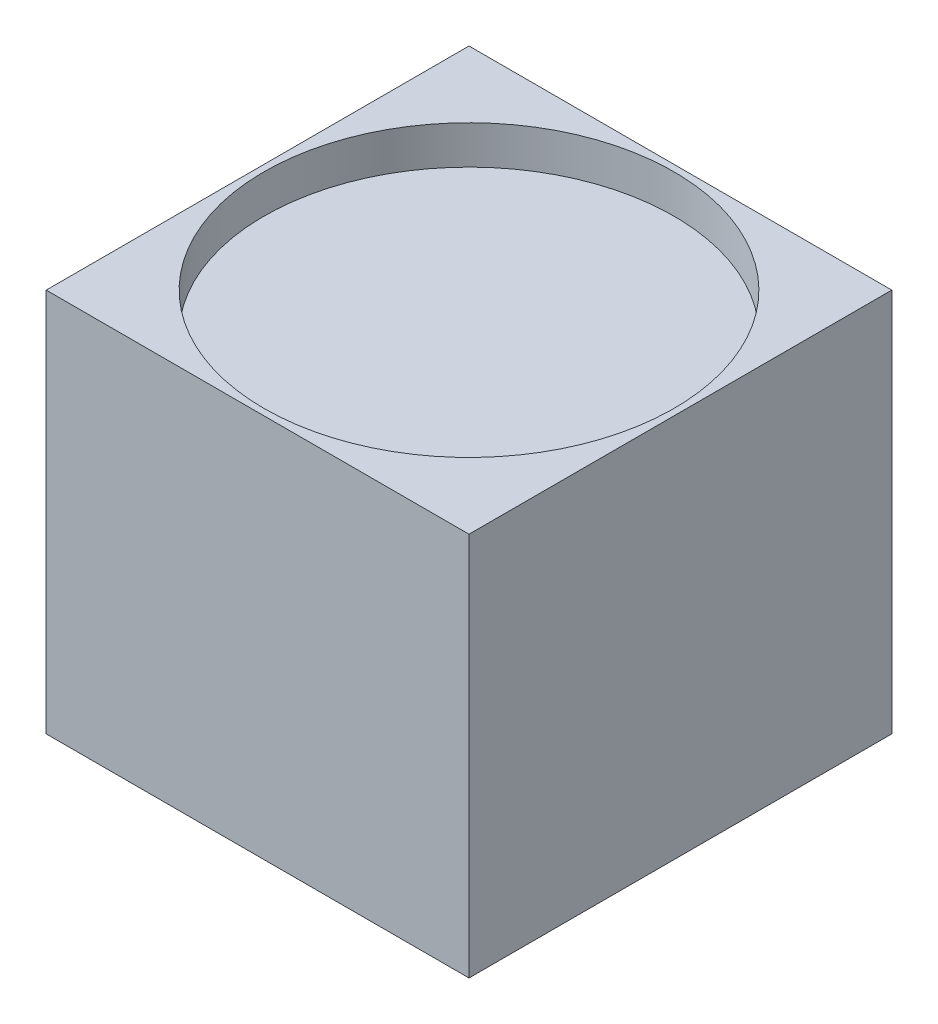
from build123d import *

# Parameters (mm, degrees)
SKETCH1_W           = 33
SKETCH1_H           = 33
BOSS_EXTRUDE1_DEPTH = 30
SKETCH2_R           = 16
CUT_EXTRUDE1_DEPTH  = 3
SKETCH3_R           = 1
CUT_EXTRUDE2_DEPTH  = 2
FILLET1_R           = 1


with BuildPart() as part:
    # Sketch1 → Boss-Extrude1 (new body)
    with BuildSketch(Plane(origin=(0, 0, 0), x_dir=(1, 0, 0), z_dir=(0, 1, 0))):
        Rectangle(SKETCH1_W, SKETCH1_H)
    extrude(amount=BOSS_EXTRUDE1_DEPTH)

    # Sketch2 → Cut-Extrude1 (cut)
    with BuildSketch(Plane(origin=(0, 30, 0), x_dir=(1, 0, 0), z_dir=(0, 1, 0))):
        Circle(SKETCH2_R)
    extrude(amount=-CUT_EXTRUDE1_DEPTH, mode=Mode.SUBTRACT)

    # Sketch3 → Cut-Extrude2 (cut)
    with BuildSketch(Plane.XZ):
        Circle(SKETCH3_R)
    extrude(amount=-CUT_EXTRUDE2_DEPTH, mode=Mode.SUBTRACT)

    # Fillet1
    fillet1_edges = [part.edges().sort_by_distance(p)[0] for p in [
        (-1, 2, 0),
    ]]
    fillet(fillet1_edges, radius=FILLET1_R)


solid = part.part
